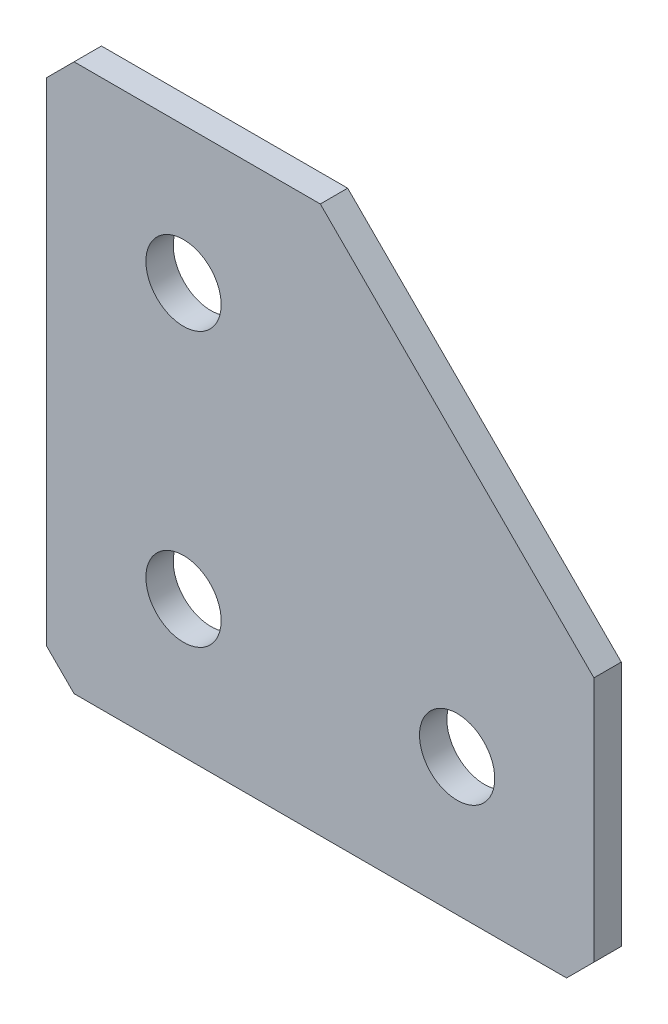
from build123d import *

# Parameters (mm, degrees)
EXTRUDE_1_DEPTH   = 2
HOLE_WIZARD_M51_D = 5.5
CHAMFER_1_SIZE    = 2


with BuildPart() as part:
    # Эскиз1 → Бобышка-Вытянуть1 (new body)
    with BuildSketch(Plane(origin=(0, 0, 0), x_dir=(1, 0, 0), z_dir=(0, 0, -1))):
        Polygon((0, 0), (0, 40), (40, 40), (40, 20), (20, 0), align=None)
    extrude(amount=EXTRUDE_1_DEPTH)

    # Отверстие с зазором M51 (through all)
    with Locations(Plane(origin=(0, 0, -2), x_dir=(1, 0, 0), z_dir=(0, 0, -1))):
        with Locations((10, 30), (10, 10), (30, 30)):
            Hole(HOLE_WIZARD_M51_D / 2)

    # Фаска1
    chamfer_1_edges = [part.edges().sort_by_distance(p)[0] for p in [
        (0, 0, -1),
        (0, -40, -1),
        (40, -40, -1),
    ]]
    chamfer(chamfer_1_edges, length=CHAMFER_1_SIZE)


solid = part.part
